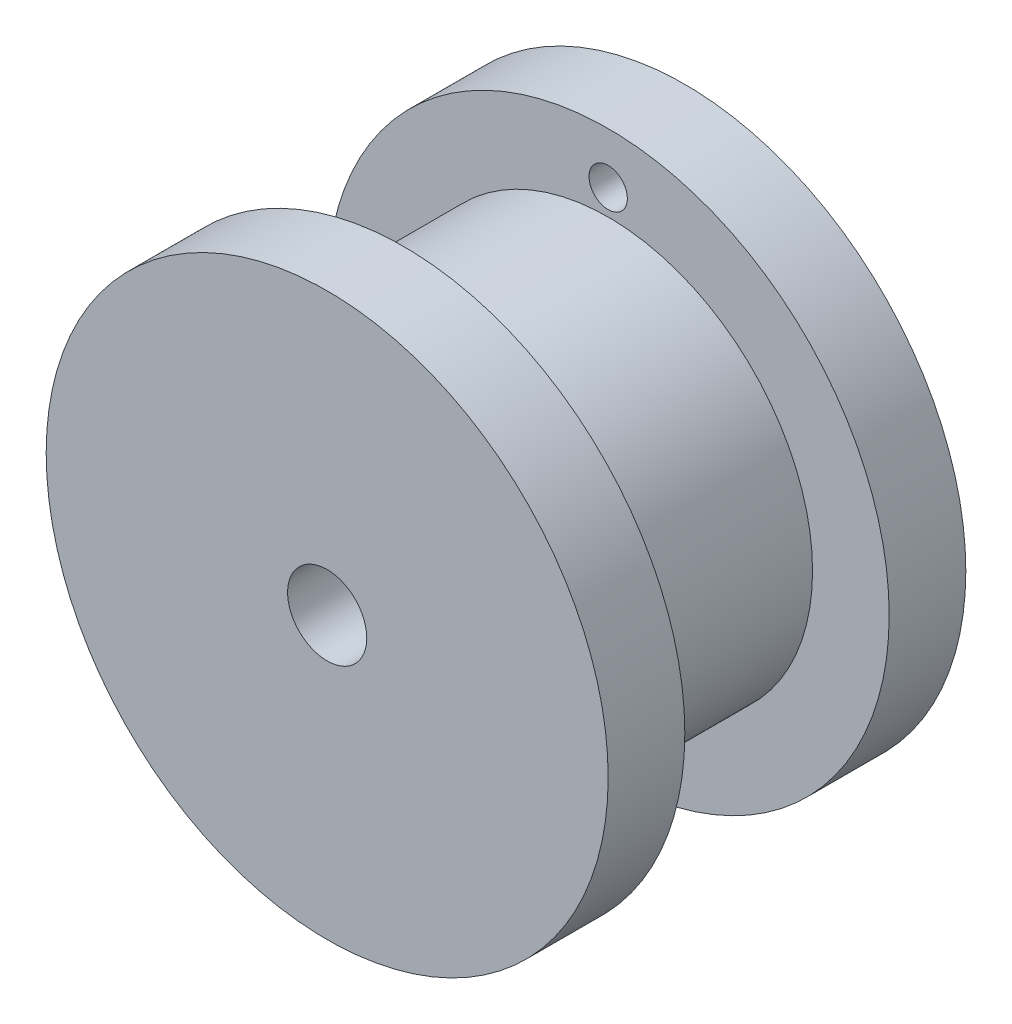
from build123d import *

# Parameters (mm, degrees)
SKETCH1_R           = 11
BOSS_EXTRUDE1_DEPTH = 3
SKETCH2_R           = 8
BOSS_EXTRUDE2_DEPTH = 8
SKETCH3_R           = 11
BOSS_EXTRUDE3_DEPTH = 3
SKETCH4_R           = 1.55
CUT_EXTRUDE1_DEPTH  = 15
SKETCH5_R           = 0.75
CUT_EXTRUDE2_DEPTH  = 4


with BuildPart() as part:
    # Sketch1 → Boss-Extrude1 (new body)
    with BuildSketch(Plane.XY):
        Circle(SKETCH1_R)
    extrude(amount=BOSS_EXTRUDE1_DEPTH)

    # Sketch2 → Boss-Extrude2 (add)
    with BuildSketch(Plane.XY.offset(3)):
        Circle(SKETCH2_R)
    extrude(amount=BOSS_EXTRUDE2_DEPTH)

    # Sketch3 → Boss-Extrude3 (add)
    with BuildSketch(Plane.XY.offset(11)):
        Circle(SKETCH3_R)
    extrude(amount=BOSS_EXTRUDE3_DEPTH)

    # Sketch4 → Cut-Extrude1 (cut, through all)
    with BuildSketch(Plane.XY.offset(14)):
        Circle(SKETCH4_R)
    extrude(amount=-CUT_EXTRUDE1_DEPTH, mode=Mode.SUBTRACT)

    # Sketch5 → Cut-Extrude2 (cut, through all)
    with BuildSketch(Plane.XY.offset(3)):
        with Locations((0, 9)):
            Circle(SKETCH5_R)
    extrude(amount=-CUT_EXTRUDE2_DEPTH, mode=Mode.SUBTRACT)


solid = part.part
